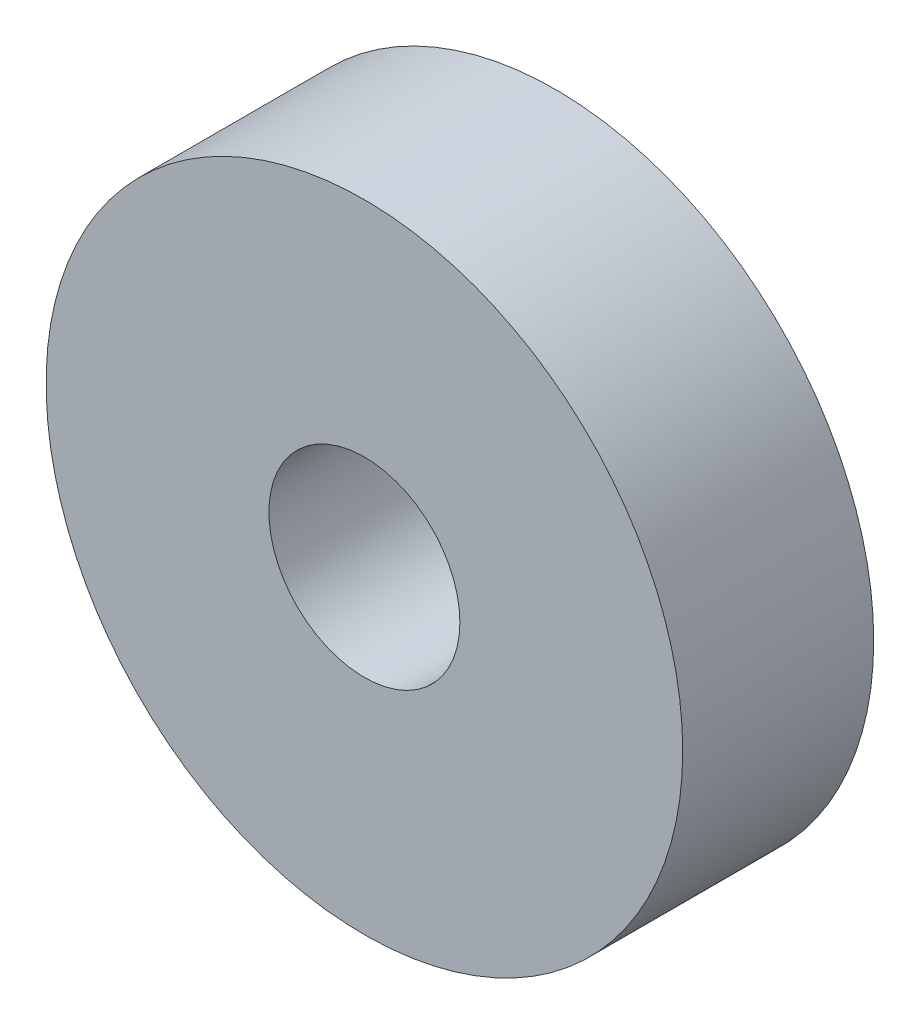
from build123d import *

# Parameters (mm, degrees)
ESQUISSE3_R        = 5
ESQUISSE3_R_2      = 1.5
BOSS_EXTRU_3_DEPTH = 3


with BuildPart() as part:
    # Esquisse3 → Boss.-Extru.3 (new body)
    with BuildSketch(Plane.XY):
        with Locations((8.931208429, 26.457848162)):
            Circle(ESQUISSE3_R)
        with Locations((8.931208429, 26.457848162)):
            Circle(ESQUISSE3_R_2, mode=Mode.SUBTRACT)
    extrude(amount=BOSS_EXTRU_3_DEPTH)


solid = part.part
